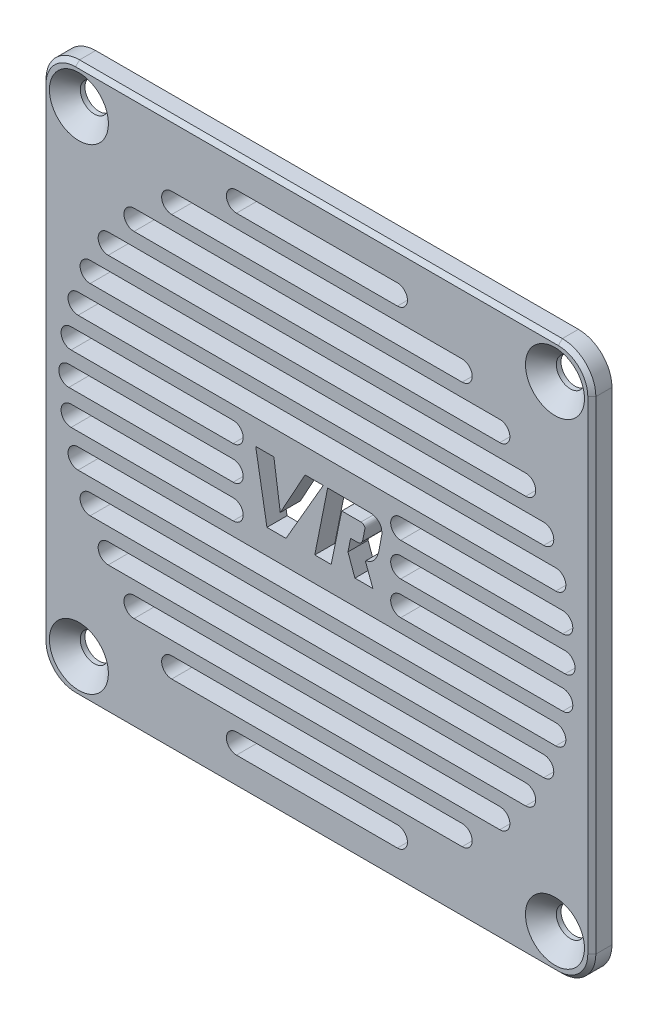
from build123d import *

# Parameters (mm, degrees)
SKETCH1_R           = 2.1
BASE_DEPTH          = 3
SCREWCHAMFER_SIZE   = 2.3
LOGO_DEPTH          = 59.060313468
SLOTS_DEPTH         = 59.060313614
OUTSIDECHAMFER_SIZE = 0.6


with BuildPart() as part:
    # Sketch1 → Base (new body)
    with BuildSketch(Plane.XY):
        with BuildLine():
            Line((41, -36), (41, 36))
            ThreePointArc((41, 36), (39.535533906, 39.535533906), (36, 41))
            Line((36, 41), (-36, 41))
            ThreePointArc((-36, 41), (-39.535533906, 39.535533906), (-41, 36))
            Line((-41, 36), (-41, -36))
            ThreePointArc((-41, -36), (-39.535533906, -39.535533906), (-36, -41))
            Line((-36, -41), (36, -41))
            ThreePointArc((36, -41), (39.535533906, -39.535533906), (41, -36))
        make_face()
        with Locations((-35.5, -35.5)):
            Circle(SKETCH1_R, mode=Mode.SUBTRACT)
        with Locations((35.5, -35.5)):
            Circle(SKETCH1_R, mode=Mode.SUBTRACT)
        with Locations((-35.5, 35.5)):
            Circle(SKETCH1_R, mode=Mode.SUBTRACT)
        with Locations((35.5, 35.5)):
            Circle(SKETCH1_R, mode=Mode.SUBTRACT)
    extrude(amount=BASE_DEPTH)

    # ScrewChamfer
    screwchamfer_edges = [part.edges().sort_by_distance(p)[0] for p in [
        (33.4, -35.5, 3),
        (-37.6, -35.5, 3),
        (33.4, 35.5, 3),
        (-37.6, 35.5, 3),
    ]]
    chamfer(screwchamfer_edges, length=SCREWCHAMFER_SIZE)

    # Sketch3 → Logo (cut, through all)
    with BuildSketch(Plane.XY.offset(3)):
        Polygon((0.943772225, 4.807339306), (-1.770278146, 4.807339306), (-5.467106691, -1.899839555), (-6.421148406, 4.807339306), (-9.131384374, 4.807339306), (-7.454751896, -4.81111301), (-4.6161142, -4.81111301), align=None)
        with BuildLine():
            Line((3.703527881, 2.889834342), (6.573462709, 2.889834342))
            add(Edge.make_bspline(
                [(6.573462709, 2.889834342), (6.639918683, 2.878954155), (6.706374657, 2.868073967), (6.772830631, 2.857193779), (6.786633549, 2.854933962), (6.814239384, 2.850414328), (6.855551453, 2.832372294), (6.876790416, 2.814167468), (6.887409897, 2.805065055), (6.919492092, 2.777566032), (6.951574286, 2.750067008), (6.983656481, 2.722567984), (6.993167085, 2.714416037), (7.012188295, 2.698112144), (7.038593103, 2.66998605), (7.051500973, 2.648514901), (7.057954908, 2.637779327), (7.075404999, 2.60875258), (7.092855089, 2.579725832), (7.11030518, 2.550699085), (7.116791727, 2.539909264), (7.12976482, 2.518329621), (7.136480315, 2.478226939), (7.136480315, 2.453047938), (7.136480315, 2.440458437), (7.136480315, 2.395991418), (7.136480315, 2.3515244), (7.136480315, 2.307057382), (7.136480315, 2.292302161), (7.136480315, 2.262791718), (7.132234446, 2.218327427), (7.1266495, 2.189350288), (7.123857028, 2.174861718), (7.033719, 1.707186218), (6.943580973, 1.239510717), (6.853442946, 0.771835216), (6.850303902, 0.755548486), (6.844025815, 0.722975025), (6.831361308, 0.674631499), (6.820862573, 0.643163717), (6.815613205, 0.627429826), (6.799830938, 0.580125754), (6.784048672, 0.532821683), (6.768266405, 0.485517611), (6.763799932, 0.472130285), (6.754866986, 0.445355633), (6.73663685, 0.405279323), (6.71826793, 0.383848917), (6.70908347, 0.373133714), (6.685410448, 0.345515187), (6.661737425, 0.317896661), (6.638064403, 0.290278135), (6.630063422, 0.280943658), (6.614061462, 0.262274704), (6.587939681, 0.235980407), (6.569486158, 0.219730482), (6.560259397, 0.21160552), (6.532062416, 0.186775636), (6.503865435, 0.161945752), (6.475668454, 0.137115868), (6.465349713, 0.128029323), (6.44471223, 0.109856232), (6.406036938, 0.091012836), (6.379877632, 0.08253595), (6.366797978, 0.078297507), (6.300222974, 0.05672397), (6.23364797, 0.035150434), (6.167072966, 0.013576897)],
                knots=[0, 0, 0, 0, 0.0565978, 0.0565978, 0.0565978, 0.068353174, 0.080108547, 0.09186392, 0.09186392, 0.09186392, 0.127377722, 0.127377722, 0.127377722, 0.13790561, 0.148433497, 0.158961384, 0.158961384, 0.158961384, 0.18742659, 0.18742659, 0.18742659, 0.198007674, 0.208588759, 0.219169844, 0.219169844, 0.219169844, 0.256542993, 0.256542993, 0.256542993, 0.268944298, 0.281345604, 0.29374691, 0.29374691, 0.29374691, 0.694047762, 0.694047762, 0.694047762, 0.70798818, 0.721928599, 0.735869017, 0.735869017, 0.735869017, 0.777780999, 0.777780999, 0.777780999, 0.789642332, 0.801503665, 0.813364999, 0.813364999, 0.813364999, 0.843937685, 0.843937685, 0.843937685, 0.854270606, 0.864603526, 0.874936447, 0.874936447, 0.874936447, 0.90651385, 0.90651385, 0.90651385, 0.918069663, 0.929625477, 0.94118129, 0.94118129, 0.94118129, 1, 1, 1, 1], degree=3))
            Line((6.167072966, 0.013576897), (5.021039356, 0.013576897))
            Line((5.021039356, 0.013576897), (4.631352863, -1.934855565))
            Line((4.631352863, -1.934855565), (5.663053903, -4.81111301))
            Line((5.663053903, -4.81111301), (8.342652792, -4.81111301))
            Line((8.342652792, -4.81111301), (7.229262814, -1.811145568))
            add(Edge.make_bspline(
                [(9.229165365, 0.414561503), (9.120168623, 0.017200275), (8.915302455, -0.554839168), (8.44639111, -1.160174748), (7.942619292, -1.563122791), (7.499335661, -1.705024341), (7.229262814, -1.811145568)],
                knots=[0, 0, 0, 0, 0.394088826, 0.566272378, 0.72213611, 1, 1, 1, 1], degree=3))
            Line((9.229165365, 0.414561503), (9.678442486, 2.846313591))
            add(Edge.make_bspline(
                [(9.678442486, 2.846313591), (9.687044519, 2.989216011), (9.687308007, 3.219249114), (9.634056055, 3.573555205), (9.530960339, 3.877016599), (9.318991652, 4.174966565), (9.058914286, 4.416757541), (8.748200867, 4.611244982), (8.404818025, 4.732990617), (8.163573675, 4.770595689), (8.033377798, 4.776411806)],
                knots=[0, 0, 0, 0, 0.150297951, 0.240095534, 0.375313148, 0.481557048, 0.620389709, 0.745312315, 0.863340897, 1, 1, 1, 1], degree=3))
            Line((8.033377798, 4.776411806), (1.600457921, 4.807339306))
            Line((1.600457921, 4.807339306), (-0.323232542, -4.81111301))
            Line((-0.323232542, -4.81111301), (2.126225411, -4.81111301))
            Line((2.126225411, -4.81111301), (3.703527881, 2.889834342))
        make_face()
    extrude(amount=-LOGO_DEPTH, mode=Mode.SUBTRACT)

    # Sketch4 → Slots (cut, through all)
    with BuildSketch(Plane.XY.offset(3)):
        with BuildLine():
            Line((-33.823069051, 13.5), (33.823069051, 13.5))
            ThreePointArc((33.823069051, 13.5), (35.323069051, 15), (33.823069051, 16.5))
            Line((33.823069051, 16.5), (-33.823069051, 16.5))
            ThreePointArc((-33.823069051, 16.5), (-35.323069051, 15), (-33.823069051, 13.5))
        make_face()
        with BuildLine():
            Line((-35.623026261, 8.5), (35.623026261, 8.5))
            ThreePointArc((35.623026261, 8.5), (37.123026261, 10), (35.623026261, 11.5))
            Line((35.623026261, 11.5), (-35.623026261, 11.5))
            ThreePointArc((-35.623026261, 11.5), (-37.123026261, 10), (-35.623026261, 8.5))
        make_face()
        with BuildLine():
            Line((-36.66060556, 3.5), (-12.5, 3.5))
            ThreePointArc((-12.5, 3.5), (-11, 5), (-12.5, 6.5))
            Line((-12.5, 6.5), (-36.66060556, 6.5))
            ThreePointArc((-36.66060556, 6.5), (-38.16060556, 5), (-36.66060556, 3.5))
        make_face()
        with BuildLine():
            Line((-36.66060556, -6.5), (-12.5, -6.5))
            ThreePointArc((-12.5, -6.5), (-11, -5), (-12.5, -3.5))
            Line((-12.5, -3.5), (-36.66060556, -3.5))
            ThreePointArc((-36.66060556, -3.5), (-38.16060556, -5), (-36.66060556, -6.5))
        make_face()
        with BuildLine():
            Line((-35.623026261, -11.5), (35.623026261, -11.5))
            ThreePointArc((35.623026261, -11.5), (37.123026261, -10), (35.623026261, -8.5))
            Line((35.623026261, -8.5), (-35.623026261, -8.5))
            ThreePointArc((-35.623026261, -8.5), (-37.123026261, -10), (-35.623026261, -11.5))
        make_face()
        with BuildLine():
            Line((-33.823069051, -16.5), (33.823069051, -16.5))
            ThreePointArc((33.823069051, -16.5), (35.323069051, -15), (33.823069051, -13.5))
            Line((33.823069051, -13.5), (-33.823069051, -13.5))
            ThreePointArc((-33.823069051, -13.5), (-35.323069051, -15), (-33.823069051, -16.5))
        make_face()
        with BuildLine():
            Line((12.5, -6.5), (36.66060556, -6.5))
            ThreePointArc((36.66060556, -6.5), (38.16060556, -5), (36.66060556, -3.5))
            Line((36.66060556, -3.5), (12.5, -3.5))
            ThreePointArc((12.5, -3.5), (11, -5), (12.5, -6.5))
        make_face()
        with BuildLine():
            Line((12.5, 3.5), (36.66060556, 3.5))
            ThreePointArc((36.66060556, 3.5), (38.16060556, 5), (36.66060556, 6.5))
            Line((36.66060556, 6.5), (12.5, 6.5))
            ThreePointArc((12.5, 6.5), (11, 5), (12.5, 3.5))
        make_face()
        with BuildLine():
            Line((-37, -1.5), (-12.5, -1.5))
            ThreePointArc((-12.5, -1.5), (-11, 0), (-12.5, 1.5))
            Line((-12.5, 1.5), (-37, 1.5))
            ThreePointArc((-37, 1.5), (-38.5, 0), (-37, -1.5))
        make_face()
        with BuildLine():
            Line((12.5, -1.5), (37, -1.5))
            ThreePointArc((37, -1.5), (38.5, 0), (37, 1.5))
            Line((37, 1.5), (12.5, 1.5))
            ThreePointArc((12.5, 1.5), (11, 0), (12.5, -1.5))
        make_face()
        with BuildLine():
            Line((-31.128764833, 18.5), (31.128764833, 18.5))
            ThreePointArc((31.128764833, 18.5), (32.628764833, 20), (31.128764833, 21.5))
            Line((31.128764833, 21.5), (-31.128764833, 21.5))
            ThreePointArc((-31.128764833, 21.5), (-32.628764833, 20), (-31.128764833, 18.5))
        make_face()
        with BuildLine():
            Line((-27.276363394, 23.5), (27.276363394, 23.5))
            ThreePointArc((27.276363394, 23.5), (28.776363394, 25), (27.276363394, 26.5))
            Line((27.276363394, 26.5), (-27.276363394, 26.5))
            ThreePointArc((-27.276363394, 26.5), (-28.776363394, 25), (-27.276363394, 23.5))
        make_face()
        with BuildLine():
            Line((-21.656407828, 28.5), (21.656407828, 28.5))
            ThreePointArc((21.656407828, 28.5), (23.156407828, 30), (21.656407828, 31.5))
            Line((21.656407828, 31.5), (-21.656407828, 31.5))
            ThreePointArc((-21.656407828, 31.5), (-23.156407828, 30), (-21.656407828, 28.5))
        make_face()
        with BuildLine():
            Line((-12, 33.5), (12, 33.5))
            ThreePointArc((12, 33.5), (13.5, 35), (12, 36.5))
            Line((12, 36.5), (-12, 36.5))
            ThreePointArc((-12, 36.5), (-13.5, 35), (-12, 33.5))
        make_face()
        with BuildLine():
            ThreePointArc((31.128764833, -18.5), (32.628764833, -20), (31.128764833, -21.5))
            Line((31.128764833, -21.5), (-31.128764833, -21.5))
            ThreePointArc((-31.128764833, -21.5), (-32.628764833, -20), (-31.128764833, -18.5))
            Line((-31.128764833, -18.5), (31.128764833, -18.5))
        make_face()
        with BuildLine():
            ThreePointArc((27.276363394, -23.5), (28.776363394, -25), (27.276363394, -26.5))
            Line((27.276363394, -26.5), (-27.276363394, -26.5))
            ThreePointArc((-27.276363394, -26.5), (-28.776363394, -25), (-27.276363394, -23.5))
            Line((-27.276363394, -23.5), (27.276363394, -23.5))
        make_face()
        with BuildLine():
            ThreePointArc((21.656407828, -28.5), (23.156407828, -30), (21.656407828, -31.5))
            Line((21.656407828, -31.5), (-21.656407828, -31.5))
            ThreePointArc((-21.656407828, -31.5), (-23.156407828, -30), (-21.656407828, -28.5))
            Line((-21.656407828, -28.5), (21.656407828, -28.5))
        make_face()
        with BuildLine():
            ThreePointArc((12, -33.5), (13.5, -35), (12, -36.5))
            Line((12, -36.5), (-12, -36.5))
            ThreePointArc((-12, -36.5), (-13.5, -35), (-12, -33.5))
            Line((-12, -33.5), (12, -33.5))
        make_face()
    extrude(amount=-SLOTS_DEPTH, mode=Mode.SUBTRACT)

    # OutsideChamfer
    outsidechamfer_edges = [part.edges().sort_by_distance(p)[0] for p in [
        (0, -41, 3),
        (-39.535533906, -39.535533906, 3),
        (39.535533906, -39.535533906, 3),
        (-41, 0, 3),
        (41, 0, 3),
        (-39.535533906, 39.535533906, 3),
        (39.535533906, 39.535533906, 3),
        (0, 41, 3),
    ]]
    chamfer(outsidechamfer_edges, length=OUTSIDECHAMFER_SIZE)


solid = part.part
